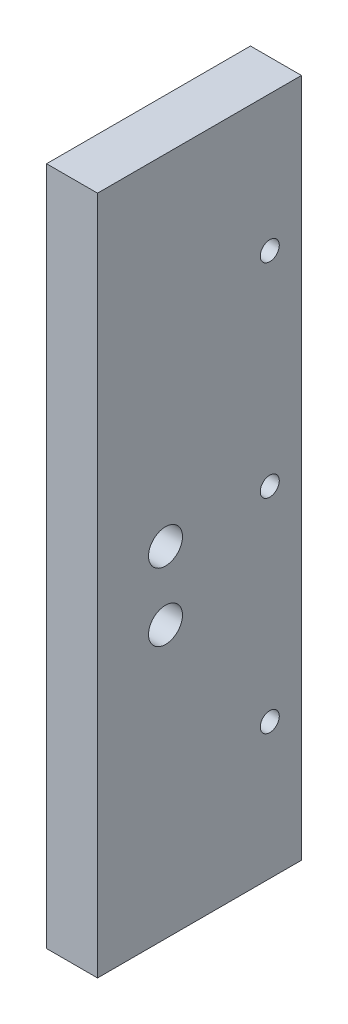
from build123d import *

# Parameters (mm, degrees)
SKETCH1_W           = 9.525
SKETCH1_H           = 127
BOSS_EXTRUDE1_DEPTH = 38.1
SKETCH2_R           = 1.778
CUT_EXTRUDE1_DEPTH  = 10.525
SKETCH3_R           = 3.175
CUT_EXTRUDE2_DEPTH  = 38.1


with BuildPart() as part:
    # Sketch1 → Boss-Extrude1 (new body)
    with BuildSketch(Plane.XY):
        with Locations((4.7625, 63.5)):
            Rectangle(SKETCH1_W, SKETCH1_H)
    extrude(amount=BOSS_EXTRUDE1_DEPTH)

    # Sketch2 → Cut-Extrude1 (cut, through all)
    with BuildSketch(Plane.ZY):
        with Locations((5.9182, 101.6)):
            Circle(SKETCH2_R)
        with Locations((5.9182, 63.5)):
            Circle(SKETCH2_R)
        with Locations((5.9182, 25.4)):
            Circle(SKETCH2_R)
    extrude(amount=-CUT_EXTRUDE1_DEPTH, mode=Mode.SUBTRACT)

    # Sketch3 → Cut-Extrude2 (cut)
    with BuildSketch(Plane(origin=(9.525, 0, 0), x_dir=(0, 0, -1), z_dir=(1, 0, 0))):
        with Locations((-25.4, 63.5)):
            Circle(SKETCH3_R)
        with Locations((-25.4, 50.8)):
            Circle(SKETCH3_R)
    extrude(amount=-CUT_EXTRUDE2_DEPTH, mode=Mode.SUBTRACT)


solid = part.part
